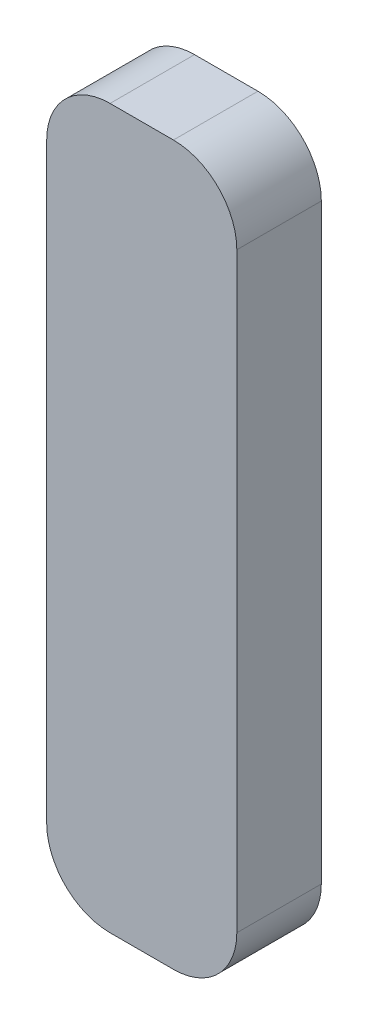
from build123d import *

# Parameters (mm, degrees)
ESQUISSE1_W        = 9
ESQUISSE1_H        = 34
BOSS_EXTRU_1_DEPTH = 4
CONG_1_R           = 3


with BuildPart() as part:
    # Esquisse1 → Boss.-Extru.1 (new body)
    with BuildSketch(Plane.XY):
        with Locations((-22.565550918, -63.216504065)):
            Rectangle(ESQUISSE1_W, ESQUISSE1_H)
    extrude(amount=BOSS_EXTRU_1_DEPTH)

    # Congé1
    cong_1_edges = [part.edges().sort_by_distance(p)[0] for p in [
        (-27.065550918, -46.216504065, 2),
        (-18.065550918, -46.216504065, 2),
        (-18.065550918, -80.216504065, 2),
        (-27.065550918, -80.216504065, 2),
    ]]
    fillet(cong_1_edges, radius=CONG_1_R)


solid = part.part
